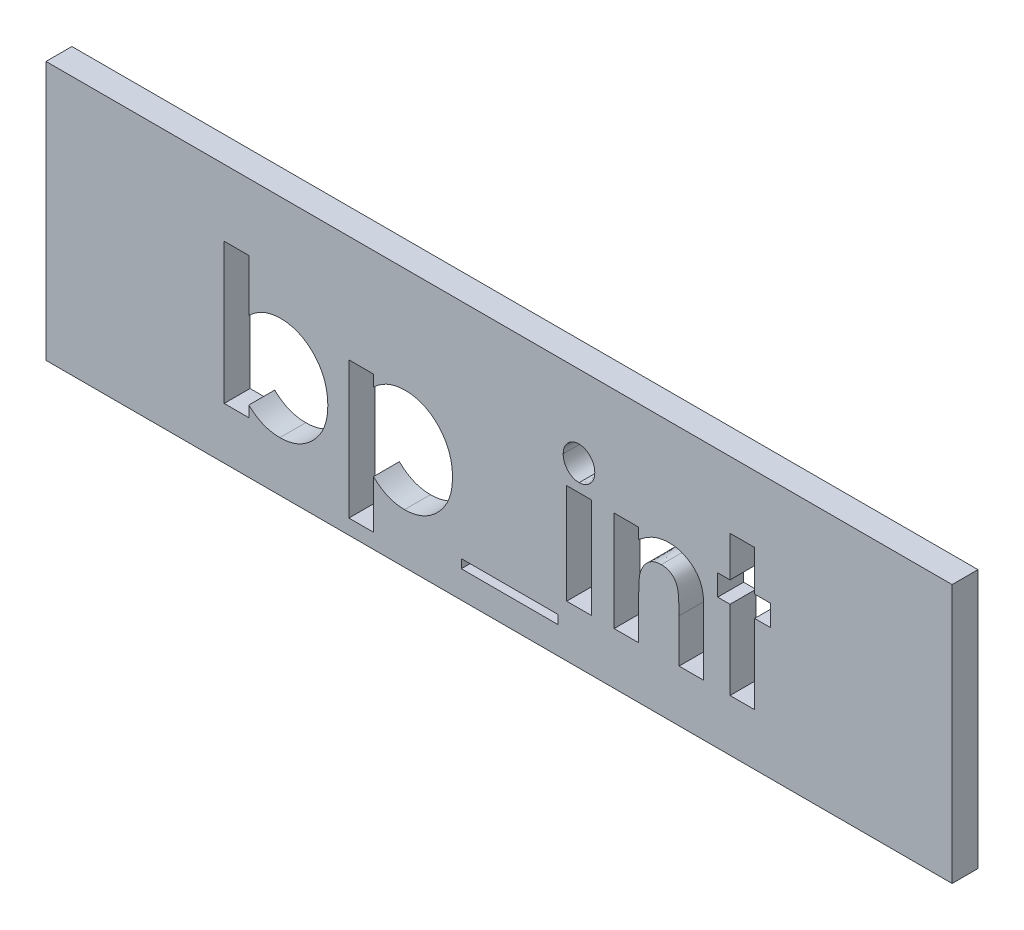
from build123d import *

# Parameters (mm, degrees)
ESQUISSE1_W             = 35
ESQUISSE1_H             = 10
BOSS_EXTRU_1_DEPTH      = 1
ESQUISSE2_R             = 1
BOSS_EXTRU_2_DEPTH      = 3
CHANFREIN1_SIZE         = 0.5
ESQUISSE3_W             = 3.731303418
ESQUISSE3_H             = 0.339209402
ESQUISSE3_W_2           = 0.949786325
ESQUISSE3_H_2           = 3.866987179
ENL_V_MAT_EXTRU_2_DEPTH = 1


with BuildPart() as part:
    # Esquisse1 → Boss.-Extru.1 (new body)
    with BuildSketch(Plane.XY):
        with Locations((17.5, -5)):
            Rectangle(ESQUISSE1_W, ESQUISSE1_H)
    extrude(amount=BOSS_EXTRU_1_DEPTH)

    # Esquisse2 → Boss.-Extru.2 (add)
    with BuildSketch(Plane(origin=(0, 0, 0), x_dir=(-1, 0, 0), z_dir=(0, 0, -1))):
        with Locations(Location((-30, -5, 0), (0, 0, 180))):  # turned: the seam where the file's is
            Circle(ESQUISSE2_R)
        with Locations(Location((-5, -5, 0), (0, 0, 180))):  # turned: the seam where the file's is
            Circle(ESQUISSE2_R)
    extrude(amount=BOSS_EXTRU_2_DEPTH)

    # Chanfrein1
    chanfrein1_edges = [part.edges().sort_by_distance(p)[0] for p in [
        (29, -5, -3),
        (4, -5, -3),
    ]]
    chamfer(chanfrein1_edges, length=CHANFREIN1_SIZE)

    # Esquisse3 → Enlèv. mat.-Extru.2 (cut)
    with BuildSketch(Plane.XY.offset(1)):
        with BuildLine():
            Line((7.832532051, -2.572649573), (7.832532051, -4.583525307))
            add(Edge.make_bspline(
                [(7.832532051, -4.583525307), (7.876635784, -4.541998984), (7.963213761, -4.460480601), (8.104571296, -4.35506841), (8.251000865, -4.266101384), (8.40237129, -4.191462211), (8.560044919, -4.136269762), (8.722084444, -4.09338316), (8.890150239, -4.070669512), (9.003806035, -4.067013922), (9.061106103, -4.06517094)],
                knots=[0, 0, 0, 0, 1.061187343, 2.083167259, 3.083809127, 4.061667593, 5.035358583, 6.007314429, 6.995378812, 8, 8, 8, 8], degree=3))
            add(Edge.make_bspline(
                [(9.061106103, -4.06517094), (9.123392054, -4.066662846), (9.246075168, -4.069601416), (9.426580027, -4.097037187), (9.599561341, -4.141385223), (9.765678734, -4.203307169), (9.924047151, -4.283702473), (10.076445975, -4.379960671), (10.220246907, -4.496053903), (10.355519854, -4.627548954), (10.4806507, -4.771677298), (10.589491492, -4.928375398), (10.680151647, -5.095580805), (10.756990584, -5.271316802), (10.813070726, -5.458497913), (10.85629262, -5.654613228), (10.880378285, -5.861321926), (10.883715437, -6.002139788), (10.885416667, -6.073926616)],
                knots=[0, 0, 0, 0, 0.985987466, 1.942075377, 2.884088208, 3.810275091, 4.743821533, 5.692411115, 6.659945104, 7.665215984, 8.677116751, 9.678438675, 10.680260931, 11.685531812, 12.710472044, 13.769734641, 14.863044265, 16, 16, 16, 16], degree=3))
            add(Edge.make_bspline(
                [(10.885416667, -6.073926616), (10.883806566, -6.14325599), (10.880632703, -6.279919471), (10.854989888, -6.480552708), (10.811527465, -6.672214326), (10.750558494, -6.854973348), (10.673050505, -7.029407327), (10.578446655, -7.195396066), (10.466195099, -7.352359771), (10.337862603, -7.498183983), (10.197640702, -7.630238647), (10.051539533, -7.748717936), (9.896649239, -7.845802422), (9.736841733, -7.927797708), (9.56959944, -7.990497917), (9.396064699, -8.03442646), (9.216512346, -8.063795417), (9.094438616, -8.066479625), (9.03248531, -8.06784188)],
                knots=[0, 0, 0, 0, 1.098553145, 2.165490463, 3.199345634, 4.208780719, 5.21409072, 6.219899742, 7.23156933, 8.267303578, 9.293302409, 10.281606823, 11.243293419, 12.184993323, 13.124258899, 14.066907486, 15.018941492, 16, 16, 16, 16], degree=3))
            add(Edge.make_bspline(
                [(9.03248531, -8.06784188), (8.977298846, -8.0663666), (8.868632688, -8.063461667), (8.708454247, -8.041916446), (8.554528582, -8.005681537), (8.404911244, -7.955767715), (8.259196273, -7.887570758), (8.11484604, -7.802299386), (7.970931538, -7.698874718), (7.87959386, -7.619174108), (7.832532051, -7.578108307)],
                knots=[0, 0, 0, 0, 0.996418773, 1.962021009, 2.912343664, 3.848616743, 4.805003894, 5.811808768, 6.872532775, 8, 8, 8, 8], degree=3))
            Line((7.832532051, -7.578108307), (7.832532051, -8))
            Line((7.832532051, -8), (6.882745726, -8))
            Line((6.882745726, -8), (6.882745726, -2.572649573))
            Line((6.882745726, -2.572649573), (7.832532051, -2.572649573))
        make_face()
        with BuildLine():
            add(Edge.make_bspline(
                [(8.855460403, -4.947115385), (8.816915241, -4.948300675), (8.741345768, -4.950624488), (8.630396019, -4.963942252), (8.525269178, -4.988999721), (8.424366877, -5.021476766), (8.328966829, -5.065315677), (8.238288554, -5.118457449), (8.15310872, -5.181824954), (8.072985246, -5.25290892), (8.000987934, -5.332878514), (7.937024568, -5.418330174), (7.883958435, -5.51037664), (7.83972203, -5.607850774), (7.806347595, -5.711807237), (7.781593433, -5.821361669), (7.768141115, -5.936849805), (7.765858679, -6.015593011), (7.764690171, -6.055906116)],
                knots=[0, 0, 0, 0, 1.060469436, 2.079096586, 3.066888298, 4.028858836, 4.99004353, 5.948472697, 6.914558426, 7.905691313, 8.889602648, 9.869280844, 10.836099585, 11.806137001, 12.808075328, 13.83377171, 14.890985086, 16, 16, 16, 16], degree=3))
            add(Edge.make_bspline(
                [(7.764690171, -6.055906116), (7.765873383, -6.096924734), (7.768195486, -6.177425538), (7.781535662, -6.295376304), (7.806116074, -6.407125617), (7.840193438, -6.512926841), (7.883677101, -6.612793704), (7.936680361, -6.707096426), (8.001347798, -6.793767468), (8.072554192, -6.875845516), (8.15317309, -6.9478806), (8.237969187, -7.012486161), (8.328944799, -7.065707146), (8.424800767, -7.108828725), (8.524809744, -7.14466252), (8.630462055, -7.168875378), (8.741328246, -7.182440126), (8.816909322, -7.18472964), (8.855460403, -7.185897436)],
                knots=[0, 0, 0, 0, 1.117193555, 2.192540452, 3.22680955, 4.227918444, 5.21468246, 6.188555072, 7.166222992, 8.154674427, 9.142376254, 10.104580718, 11.053462639, 12.005072638, 12.963662044, 13.941614018, 14.950094269, 16, 16, 16, 16], degree=3))
            add(Edge.make_bspline(
                [(8.855460403, -7.185897436), (8.892609201, -7.184812589), (8.966142511, -7.182665216), (9.073734201, -7.167681595), (9.177156619, -7.14319687), (9.275599833, -7.10829728), (9.369663104, -7.062858049), (9.460202757, -7.009686628), (9.544093023, -6.943252907), (9.624625057, -6.870236576), (9.696679712, -6.787895155), (9.761321397, -6.70041824), (9.815622334, -6.607025082), (9.858735998, -6.507405975), (9.894379294, -6.403447851), (9.918714096, -6.293247915), (9.932102658, -6.177789782), (9.934442765, -6.099047168), (9.935630342, -6.059086205)],
                knots=[0, 0, 0, 0, 1.021711385, 2.02240246, 2.981887075, 3.941027022, 4.888772411, 5.852236371, 6.822344989, 7.82661704, 8.838806642, 9.826383926, 10.814965113, 11.80282933, 12.807900643, 13.833672313, 14.900613836, 16, 16, 16, 16], degree=3))
            add(Edge.make_bspline(
                [(9.935630342, -6.059086205), (9.9344238, -6.019484756), (9.932046574, -5.941458813), (9.918932181, -5.826962137), (9.893660452, -5.718364319), (9.861751677, -5.614778194), (9.817172259, -5.517552184), (9.764461591, -5.425536121), (9.702437725, -5.338452168), (9.630487368, -5.258651167), (9.551570508, -5.186037989), (9.467328103, -5.121811034), (9.378090983, -5.067135595), (9.282643931, -5.024017819), (9.183239349, -4.988541182), (9.078358128, -4.964104405), (8.968533472, -4.950579726), (8.89365765, -4.948285675), (8.855460403, -4.947115385)],
                knots=[0, 0, 0, 0, 1.094680664, 2.156827393, 3.177782763, 4.17210342, 5.146667393, 6.126451192, 7.099203661, 8.094961544, 9.09004898, 10.058676268, 11.018205477, 11.974998356, 12.947750825, 13.930643515, 14.944335875, 16, 16, 16, 16], degree=3))
        make_face(mode=Mode.SUBTRACT)
        with BuildLine():
            Line((12.649305556, -4.133012821), (12.649305556, -4.568684896))
            add(Edge.make_bspline(
                [(12.649305556, -4.568684896), (12.693399961, -4.528171753), (12.779996824, -4.448608122), (12.921779315, -4.346742923), (13.067482227, -4.259256524), (13.219782696, -4.188889417), (13.376590603, -4.133445707), (13.539311036, -4.09448843), (13.706747667, -4.068795061), (13.820542622, -4.066385185), (13.877879607, -4.06517094)],
                knots=[0, 0, 0, 0, 1.054376801, 2.070687235, 3.070225973, 4.045259405, 5.022040922, 5.996139433, 6.99033025, 8, 8, 8, 8], degree=3))
            add(Edge.make_bspline(
                [(13.877879607, -4.06517094), (13.940165559, -4.066662846), (14.062848672, -4.069601416), (14.243353531, -4.097037187), (14.416334846, -4.141385223), (14.582452239, -4.203307169), (14.740820656, -4.283702473), (14.893219479, -4.379960671), (15.037020411, -4.496053903), (15.172293358, -4.627548954), (15.297424205, -4.771677298), (15.406264996, -4.928375398), (15.496925152, -5.095580805), (15.573764088, -5.271316802), (15.62984423, -5.458497913), (15.673066124, -5.654613228), (15.697151789, -5.861321926), (15.700488941, -6.002139788), (15.702190171, -6.073926616)],
                knots=[0, 0, 0, 0, 0.985987466, 1.942075377, 2.884088208, 3.810275091, 4.743821533, 5.692411115, 6.659945104, 7.665215984, 8.677116751, 9.678438675, 10.680260931, 11.685531812, 12.710472044, 13.769734641, 14.863044265, 16, 16, 16, 16], degree=3))
            add(Edge.make_bspline(
                [(15.702190171, -6.073926616), (15.70058007, -6.14325599), (15.697406207, -6.279919471), (15.671763393, -6.480552708), (15.62830097, -6.672214326), (15.567331998, -6.854973348), (15.489824009, -7.029407327), (15.395220159, -7.195396066), (15.282968603, -7.352359771), (15.154636108, -7.498183983), (15.014414207, -7.630238647), (14.868313037, -7.748717936), (14.713422743, -7.845802422), (14.553615237, -7.927797708), (14.386372944, -7.990497917), (14.212838203, -8.03442646), (14.03328585, -8.063795417), (13.91121212, -8.066479625), (13.849258814, -8.06784188)],
                knots=[0, 0, 0, 0, 1.098553145, 2.165490463, 3.199345634, 4.208780719, 5.21409072, 6.219899742, 7.23156933, 8.267303578, 9.293302409, 10.281606823, 11.243293419, 12.184993323, 13.124258899, 14.066907486, 15.018941492, 16, 16, 16, 16], degree=3))
            add(Edge.make_bspline(
                [(13.849258814, -8.06784188), (13.794051249, -8.066502987), (13.685295667, -8.063865449), (13.525373115, -8.040348446), (13.370886114, -8.005222037), (13.221630308, -7.952352875), (13.075927796, -7.882195943), (12.931297082, -7.794828168), (12.787403727, -7.688093559), (12.696325922, -7.605769171), (12.649305556, -7.563267895)],
                knots=[0, 0, 0, 0, 0.990856396, 1.951927477, 2.896945079, 3.83213376, 4.788585491, 5.796263726, 6.862286081, 8, 8, 8, 8], degree=3))
            Line((12.649305556, -7.563267895), (12.649305556, -9.424679487))
            Line((12.649305556, -9.424679487), (11.699519231, -9.424679487))
            Line((11.699519231, -9.424679487), (11.699519231, -4.133012821))
            Line((11.699519231, -4.133012821), (12.649305556, -4.133012821))
        make_face()
        with BuildLine():
            add(Edge.make_bspline(
                [(13.672233908, -4.947115385), (13.633688745, -4.948300675), (13.558119272, -4.950624488), (13.447169523, -4.963942252), (13.342042682, -4.988999721), (13.241140381, -5.021476766), (13.145740333, -5.065315677), (13.055062058, -5.118457449), (12.969882224, -5.181824954), (12.88975875, -5.25290892), (12.817761438, -5.332878514), (12.753798072, -5.418330174), (12.700731939, -5.51037664), (12.656495534, -5.607850774), (12.623121099, -5.711807237), (12.598366937, -5.821361669), (12.58491462, -5.936849805), (12.582632184, -6.015593011), (12.581463675, -6.055906116)],
                knots=[0, 0, 0, 0, 1.060469436, 2.079096586, 3.066888298, 4.028858836, 4.99004353, 5.948472697, 6.914558426, 7.905691313, 8.889602648, 9.869280844, 10.836099585, 11.806137001, 12.808075328, 13.83377171, 14.890985086, 16, 16, 16, 16], degree=3))
            add(Edge.make_bspline(
                [(12.581463675, -6.055906116), (12.582646887, -6.096924734), (12.584968991, -6.177425538), (12.598309166, -6.295376304), (12.622889579, -6.407125617), (12.656966942, -6.512926841), (12.700450606, -6.612793704), (12.753453865, -6.707096426), (12.818121302, -6.793767468), (12.889327697, -6.875845516), (12.969946594, -6.9478806), (13.054742691, -7.012486161), (13.145718303, -7.065707146), (13.241574271, -7.108828725), (13.341583248, -7.14466252), (13.447235559, -7.168875378), (13.55810175, -7.182440126), (13.633682826, -7.18472964), (13.672233908, -7.185897436)],
                knots=[0, 0, 0, 0, 1.117193555, 2.192540452, 3.22680955, 4.227918444, 5.21468246, 6.188555072, 7.166222992, 8.154674427, 9.142376254, 10.104580718, 11.053462639, 12.005072638, 12.963662044, 13.941614018, 14.950094269, 16, 16, 16, 16], degree=3))
            add(Edge.make_bspline(
                [(13.672233908, -7.185897436), (13.709382705, -7.184812589), (13.782916015, -7.182665216), (13.890507705, -7.167681595), (13.993930123, -7.14319687), (14.092373337, -7.10829728), (14.186436608, -7.062858049), (14.276976261, -7.009686628), (14.360866527, -6.943252907), (14.441398561, -6.870236576), (14.513453216, -6.787895155), (14.578094902, -6.70041824), (14.632395839, -6.607025082), (14.675509503, -6.507405975), (14.711152798, -6.403447851), (14.7354876, -6.293247915), (14.748876162, -6.177789782), (14.751216269, -6.099047168), (14.752403846, -6.059086205)],
                knots=[0, 0, 0, 0, 1.021711385, 2.02240246, 2.981887075, 3.941027022, 4.888772411, 5.852236371, 6.822344989, 7.82661704, 8.838806642, 9.826383926, 10.814965113, 11.80282933, 12.807900643, 13.833672313, 14.900613836, 16, 16, 16, 16], degree=3))
            add(Edge.make_bspline(
                [(14.752403846, -6.059086205), (14.751197304, -6.019484756), (14.748820078, -5.941458813), (14.735705685, -5.826962137), (14.710433956, -5.718364319), (14.678525182, -5.614778194), (14.633945763, -5.517552184), (14.581235096, -5.425536121), (14.519211229, -5.338452168), (14.447260872, -5.258651167), (14.368344012, -5.186037989), (14.284101608, -5.121811034), (14.194864487, -5.067135595), (14.099417436, -5.024017819), (14.000012854, -4.988541182), (13.895131632, -4.964104405), (13.785306976, -4.950579726), (13.710431154, -4.948285675), (13.672233908, -4.947115385)],
                knots=[0, 0, 0, 0, 1.094680664, 2.156827393, 3.177782763, 4.17210342, 5.146667393, 6.126451192, 7.099203661, 8.094961544, 9.09004898, 10.058676268, 11.018205477, 11.974998356, 12.947750825, 13.930643515, 14.944335875, 16, 16, 16, 16], degree=3))
        make_face(mode=Mode.SUBTRACT)
        with Locations((17.907051282, -8.780181624)):
            Rectangle(ESQUISSE3_W, ESQUISSE3_H)
        with BuildLine():
            add(Edge.make_bspline(
                [(20.584685497, -2.504807692), (20.625621281, -2.506816157), (20.706002636, -2.51075997), (20.821159867, -2.549203379), (20.926850866, -2.609539161), (21.02028464, -2.692321292), (21.097994117, -2.791178297), (21.157367043, -2.901855287), (21.190441227, -3.024481827), (21.195034741, -3.109190958), (21.197382479, -3.152485644)],
                knots=[0, 0, 0, 0, 0.989868614, 1.943702388, 2.910836514, 3.924849579, 4.949916355, 5.946401046, 6.950409252, 8, 8, 8, 8], degree=3))
            add(Edge.make_bspline(
                [(21.197382479, -3.152485644), (21.195118739, -3.195461271), (21.190707736, -3.279201328), (21.15660582, -3.400163155), (21.099615917, -3.510786389), (21.021277042, -3.608175184), (20.928856212, -3.68962406), (20.825474642, -3.751055201), (20.711420952, -3.787360012), (20.632286872, -3.791633507), (20.592105702, -3.793803419)],
                knots=[0, 0, 0, 0, 1.05296456, 2.051751585, 3.055639087, 4.085634717, 5.099016424, 6.062201612, 7.016062274, 8, 8, 8, 8], degree=3))
            add(Edge.make_bspline(
                [(20.592105702, -3.793803419), (20.550812583, -3.791802134), (20.469731913, -3.787872533), (20.353630156, -3.749339175), (20.246529509, -3.689478577), (20.15350105, -3.605005079), (20.074901627, -3.50544562), (20.018122133, -3.392191974), (19.982605156, -3.268726916), (19.978389322, -3.182763185), (19.976228632, -3.138705262)],
                knots=[0, 0, 0, 0, 0.989065327, 1.942068821, 2.907541208, 3.917690034, 4.939857478, 5.938239964, 6.943311734, 8, 8, 8, 8], degree=3))
            add(Edge.make_bspline(
                [(19.976228632, -3.138705262), (19.978580053, -3.096459386), (19.983199079, -3.013473462), (20.016471381, -2.893573269), (20.074482888, -2.784756933), (20.151632615, -2.687709598), (20.244245726, -2.606471665), (20.349873277, -2.547968321), (20.464255496, -2.511112734), (20.544127664, -2.506931074), (20.584685497, -2.504807692)],
                knots=[0, 0, 0, 0, 1.038616768, 2.040212704, 3.031499824, 4.052181184, 5.074969369, 6.039807101, 7.004644834, 8, 8, 8, 8], degree=3))
        make_face()
        with Locations((20.586805555, -6.066506411)):
            Rectangle(ESQUISSE3_W_2, ESQUISSE3_H_2)
        with BuildLine():
            Line((21.943643162, -4.133012821), (22.893429487, -4.133012821))
            Line((22.893429487, -4.133012821), (22.893429487, -4.542184161))
            add(Edge.make_bspline(
                [(22.893429487, -4.542184161), (22.947614326, -4.500038078), (23.051172087, -4.419488718), (23.208597763, -4.316787875), (23.35718811, -4.232731359), (23.500255367, -4.168793671), (23.640491347, -4.122793254), (23.780167273, -4.089744699), (23.921363203, -4.0685828), (24.01628114, -4.066307617), (24.063701923, -4.06517094)],
                knots=[0, 0, 0, 0, 1.276643801, 2.439914479, 3.493451431, 4.44993799, 5.350072675, 6.235028322, 7.118224225, 8, 8, 8, 8], degree=3))
            add(Edge.make_bspline(
                [(24.063701923, -4.06517094), (24.111803926, -4.066469926), (24.206232196, -4.069019945), (24.345272622, -4.086855259), (24.478112245, -4.119339015), (24.606244739, -4.162468657), (24.728365933, -4.219397312), (24.845971888, -4.286990852), (24.956536467, -4.369324358), (25.02462703, -4.432025603), (25.059069511, -4.463741987)],
                knots=[0, 0, 0, 0, 1.048836932, 2.058954983, 3.049370783, 4.026390553, 5.001981509, 5.982488534, 6.97947532, 8, 8, 8, 8], degree=3))
            add(Edge.make_bspline(
                [(25.059069511, -4.463741987), (25.086693649, -4.493133801), (25.1421441, -4.55213254), (25.211921525, -4.653094495), (25.271798405, -4.763161505), (25.320859187, -4.88360323), (25.35711313, -5.015081418), (25.385003782, -5.156008001), (25.400653713, -5.307172064), (25.402585771, -5.411020349), (25.40357906, -5.464409722)],
                knots=[0, 0, 0, 0, 0.889584746, 1.785680191, 2.700364693, 3.65222533, 4.649950538, 5.707241244, 6.821271309, 8, 8, 8, 8], degree=3))
            Line((25.40357906, -5.464409722), (25.40357906, -8))
            Line((25.40357906, -8), (24.453792735, -8))
            Line((24.453792735, -8), (24.453792735, -6.320913462))
            add(Edge.make_bspline(
                [(24.453792735, -6.320913462), (24.453591876, -6.266144584), (24.453206968, -6.161190195), (24.45025172, -6.010984692), (24.444481357, -5.875329616), (24.439221821, -5.753977979), (24.428895261, -5.647360661), (24.419582602, -5.554802693), (24.405293229, -5.477143768), (24.386700438, -5.393609941), (24.354232845, -5.304171704), (24.303828489, -5.209933745), (24.239883496, -5.129876499), (24.165009634, -5.063438723), (24.079289595, -5.010880348), (23.983759182, -4.973902258), (23.878930551, -4.950856604), (23.805887192, -4.948394187), (23.767953726, -4.947115385)],
                knots=[0, 0, 0, 0, 1.49886392, 2.872294502, 4.110984203, 5.214877267, 6.195405875, 7.042225351, 7.75923308, 8.355011229, 9.382752534, 10.352059385, 11.267231453, 12.171456522, 13.078624015, 14.003401117, 14.963110155, 16, 16, 16, 16], degree=3))
            add(Edge.make_bspline(
                [(23.767953726, -4.947115385), (23.718619657, -4.949617128), (23.622112629, -4.954511026), (23.482534518, -4.991415476), (23.35433435, -5.054179082), (23.238559623, -5.141031292), (23.136312997, -5.248261109), (23.052099962, -5.376144965), (22.983027974, -5.521596392), (22.953325992, -5.62779956), (22.937950721, -5.682775775)],
                knots=[0, 0, 0, 0, 0.984188326, 1.925263693, 2.85911992, 3.81709677, 4.80007086, 5.801799564, 6.862098548, 8, 8, 8, 8], degree=3))
            add(Edge.make_bspline(
                [(22.937950721, -5.682775775), (22.934129355, -5.700041423), (22.925606941, -5.738547291), (22.918598334, -5.803598745), (22.908848853, -5.880775998), (22.905195962, -5.971475739), (22.898843986, -6.075268725), (22.896494722, -6.192292272), (22.894141254, -6.322316916), (22.893674603, -6.41313419), (22.893429487, -6.46083734)],
                knots=[0, 0, 0, 0, 0.543362196, 1.211806945, 2.009705693, 2.934833164, 4.000995085, 5.207458376, 6.533175157, 8, 8, 8, 8], degree=3))
            Line((22.893429487, -6.46083734), (22.893429487, -8))
            Line((22.893429487, -8), (21.943643162, -8))
            Line((21.943643162, -8), (21.943643162, -4.133012821))
        make_face()
        Polygon((26.421207265, -2.572649573), (27.37099359, -2.572649573), (27.37099359, -4.133012821), (27.981570513, -4.133012821), (27.981570513, -4.947115385), (27.37099359, -4.947115385), (27.37099359, -8), (26.421207265, -8), (26.421207265, -4.947115385), (25.946314103, -4.947115385), (25.946314103, -4.133012821), (26.421207265, -4.133012821), align=None)
    extrude(amount=-ENL_V_MAT_EXTRU_2_DEPTH, mode=Mode.SUBTRACT)


with BuildPart() as body_2:
    # of the pieces the cut leaves, the one that is kept (enl_v_mat_extru_2_keep)
    add(part.part.solids().sort_by_distance((31, -5, -2.5))[0])


solid = body_2.part
